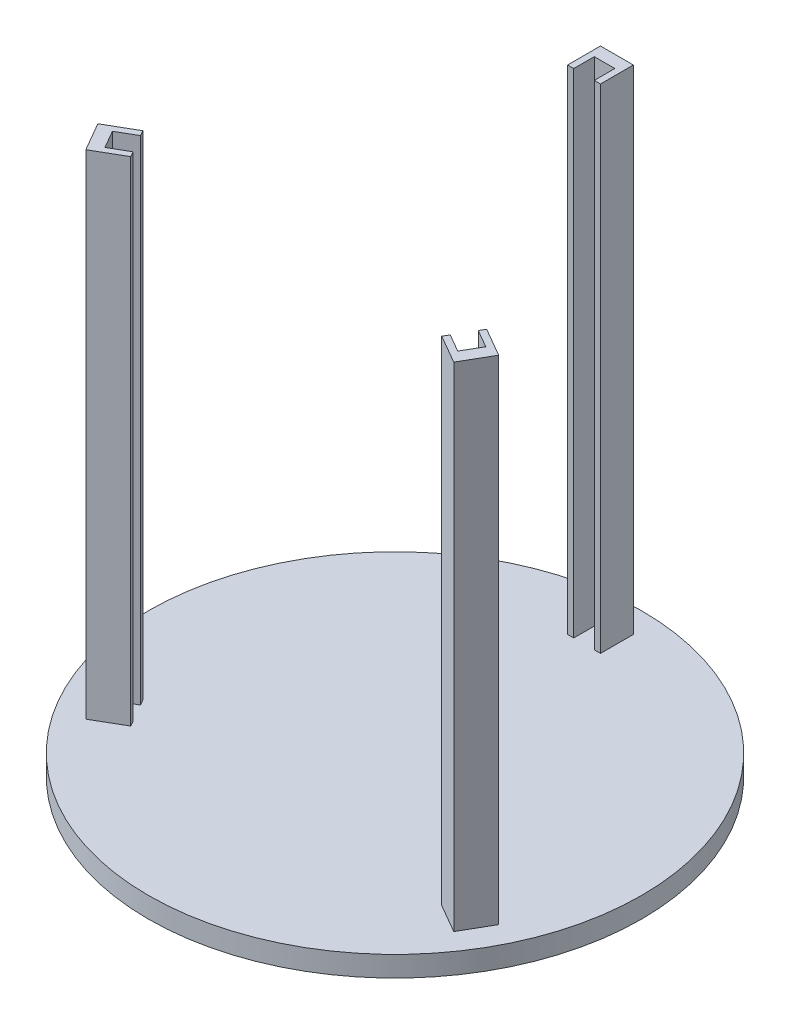
from build123d import *

# Parameters (mm, degrees)
SKETCH2_R           = 300
BOSS_EXTRUDE1_DEPTH = 25
SKETCH4_W           = 40
SKETCH4_H           = 40
BOSS_EXTRUDE2_DEPTH = 600
SKETCH5_W           = 25
SKETCH5_H           = 25
CUT_EXTRUDE3_DEPTH  = 600
CIRPATTERN2_COUNT   = 3


with BuildPart() as part:
    # Sketch2 → Boss-Extrude1 (new body)
    with BuildSketch(Plane(origin=(0, 0, 0), x_dir=(1, 0, 0), z_dir=(0, 1, 0))):
        Circle(SKETCH2_R)
    extrude(amount=BOSS_EXTRUDE1_DEPTH)

    # Sketch4 → Boss-Extrude2 (add)
    with BuildSketch(Plane(origin=(0, 25, 0), x_dir=(1, 0, 0), z_dir=(0, 1, 0))):
        with Locations((0, 250)):
            Rectangle(SKETCH4_W, SKETCH4_H)
    boss_extrude2 = extrude(amount=BOSS_EXTRUDE2_DEPTH)

    # Sketch5 → Cut-Extrude3 (cut)
    with BuildSketch(Plane(origin=(0, 625, 0), x_dir=(1, 0, 0), z_dir=(0, 1, 0))):
        with Locations((-0.042882398, 242.5)):
            Rectangle(SKETCH5_W, SKETCH5_H)
    cut_extrude3 = extrude(amount=-CUT_EXTRUDE3_DEPTH, mode=Mode.SUBTRACT)

    # CirPattern2: Boss-Extrude2, Cut-Extrude3 ×3 about axis
    cirpattern2_axis = Axis((0, 0, 0), (0, 1, 0))
    for i in range(1, CIRPATTERN2_COUNT):
        add(boss_extrude2.rotate(cirpattern2_axis, i * 360 / CIRPATTERN2_COUNT))
        add(cut_extrude3.rotate(cirpattern2_axis, i * 360 / CIRPATTERN2_COUNT), mode=Mode.SUBTRACT)


solid = part.part
